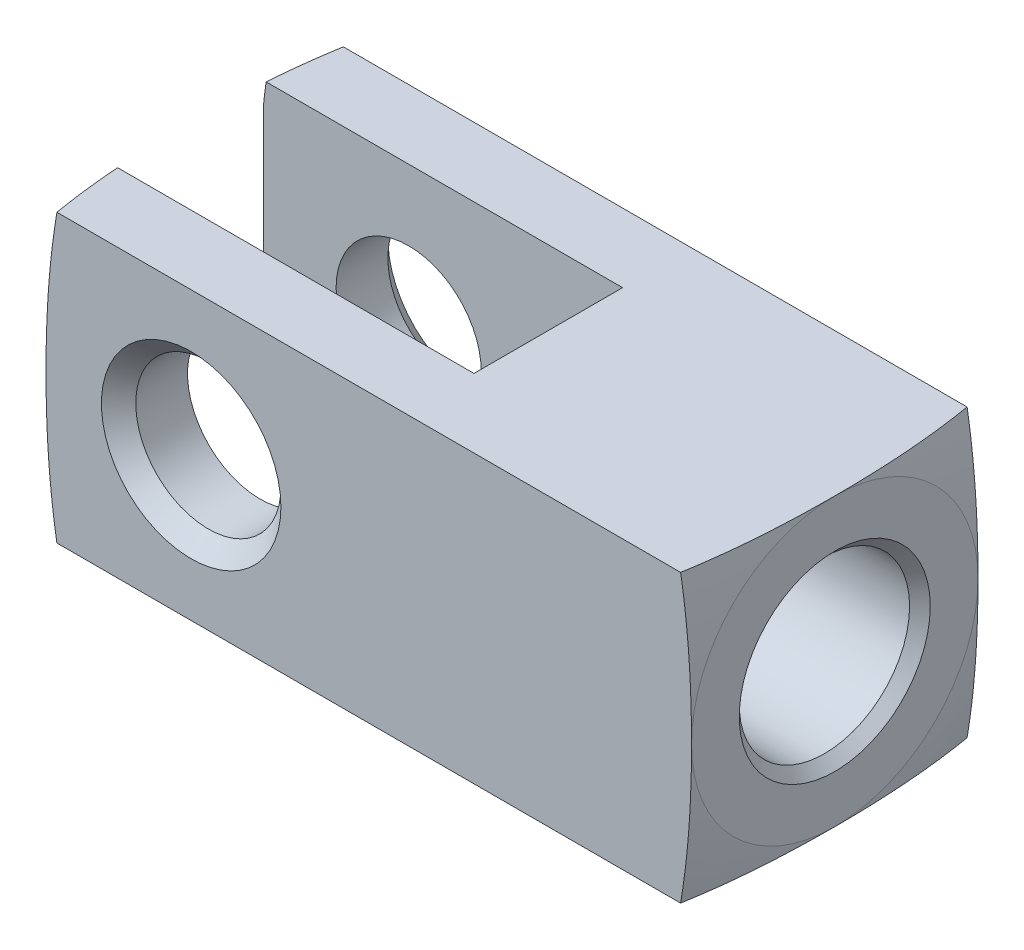
from build123d import *

# Parameters (mm, degrees)
BOSS_EXTRUDE1_DEPTH      = 9.525
BOSS_EXTRUDE1_DEPTH_BACK = 9.525
SKETCH1_W                = 42.926
SKETCH1_H                = 19.05
CUT_EXTRUDE1_DEPTH       = 9.525
CUT_EXTRUDE1_DEPTH_BACK  = 9.525
SKETCH2_W                = 23.876
SKETCH2_H                = 9.8806
HOLE1_D                  = 11.32586
HOLE1_DEPTH              = 19.05
HOLE1_CSINK_D            = 12.7
HOLE1_CSINK_ANGLE        = 90


with BuildPart() as part:
    # Sketch1 → Boss-Extrude1 (new, two sides: drawn at the far end of the back side and taken through both)
    with BuildSketch(Plane.XY.offset(-BOSS_EXTRUDE1_DEPTH_BACK)):
        with Locations((11.811, 0)):
            Rectangle(SKETCH1_W, SKETCH1_H)
    extrude(amount=BOSS_EXTRUDE1_DEPTH + BOSS_EXTRUDE1_DEPTH_BACK)

    # Sketch2 → Cut-Extrude1 (cut, two sides: drawn at the far end of the back side and taken through both)
    with BuildSketch(Plane(origin=(0, 0, 0), x_dir=(1, 0, 0), z_dir=(0, 1, 0)).offset(-CUT_EXTRUDE1_DEPTH_BACK)):
        with Locations((2.286, 0)):
            Rectangle(SKETCH2_W, SKETCH2_H)
    extrude(amount=CUT_EXTRUDE1_DEPTH + CUT_EXTRUDE1_DEPTH_BACK, mode=Mode.SUBTRACT)

    # Hole1
    with Locations(Plane(origin=(33.274, 0, 0), x_dir=(0, 0, -1), z_dir=(1, 0, 0))):
        with Locations((0, 0)):
            CounterSinkHole(HOLE1_D / 2, HOLE1_CSINK_D / 2, depth=HOLE1_DEPTH, counter_sink_angle=HOLE1_CSINK_ANGLE)

    # Sketch5 → Cut-Revolve1 (revolve, cut)
    with BuildSketch(Plane(origin=(0, 0, 0), x_dir=(0, 0, -1), z_dir=(1, 0, 0))):
        Polygon((-9.525, 0), (-9.525, 5.969), (-8.382, 4.826), (8.382, 4.826), (9.525, 5.969), (9.525, 0), align=None)
    revolve(axis=Axis((0, 0, -9.525), (0, 0, 1)), mode=Mode.SUBTRACT)

    # Sketch6 → Cut-Revolve2 (revolve, cut)
    with BuildSketch(Plane.XY):
        with BuildLine():
            Line((33.274, 0), (33.274, 9.525))
            ThreePointArc((33.274, 9.525), (32.320101294, 14.371793679), (30.734, 19.05))
            Line((30.734, 19.05), (42.799, 19.05))
            Line((42.799, 19.05), (42.799, 0))
            Line((42.799, 0), (33.274, 0))
        make_face()
    revolve(axis=Axis((42.799, 0, 0), (-1, 0, 0)), mode=Mode.SUBTRACT)

    # Sketch7 → Cut-Revolve3 (revolve, cut)
    with BuildSketch(Plane.XY):
        with BuildLine():
            Line((-19.177, 0), (-19.177, 19.05))
            Line((-19.177, 19.05), (-7.112, 19.05))
            ThreePointArc((-7.112, 19.05), (-8.698101294, 14.371793679), (-9.652, 9.525))
            Line((-9.652, 9.525), (-9.652, 0))
            Line((-9.652, 0), (-19.177, 0))
        make_face()
    revolve(axis=Axis((-9.652, 0, 0), (-1, 0, 0)), mode=Mode.SUBTRACT)


solid = part.part
